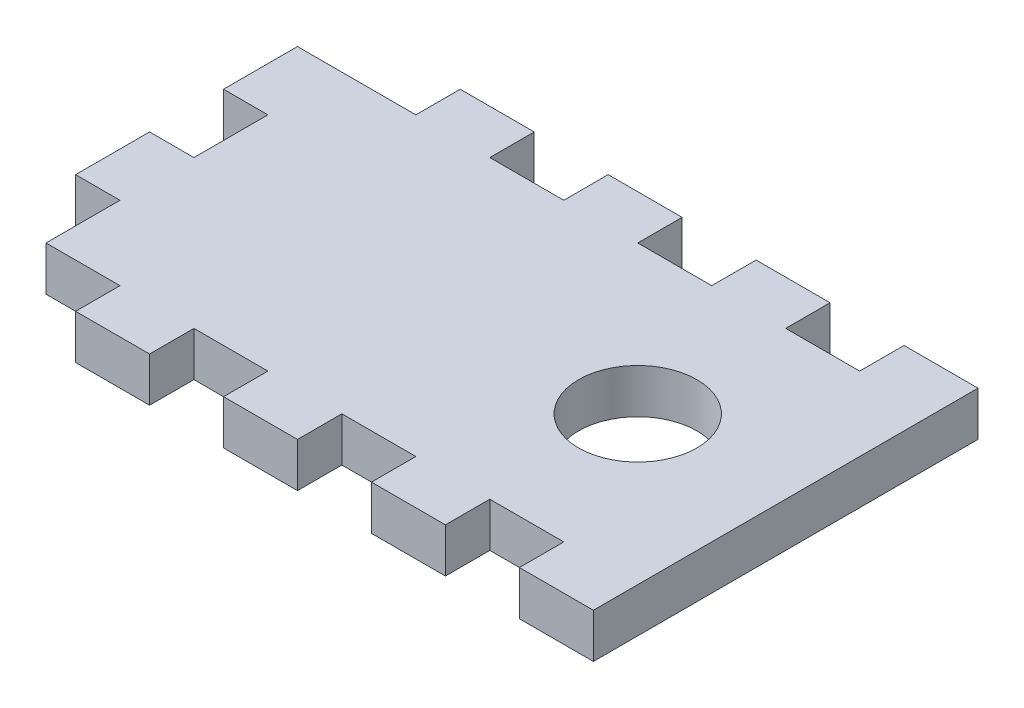
from build123d import *

# Parameters (mm, degrees)
SKETCH1_W           = 40
SKETCH1_H           = 26
BOSS_EXTRUDE1_DEPTH = 1.5
SKETCH2_R           = 4
CUT_EXTRUDE1_DEPTH  = 3
SKETCH8_W           = 5
SKETCH8_H           = 3
BOSS_EXTRUDE7_DEPTH = 3
SKETCH9_W           = 5
SKETCH9_H           = 3
CUT_EXTRUDE2_DEPTH  = 3


with BuildPart() as part:
    # Sketch1 → Boss-Extrude1 (new body, symmetric)
    with BuildSketch(Plane(origin=(0, 0, 0), x_dir=(1, 0, 0), z_dir=(0, 1, 0))):
        Rectangle(SKETCH1_W, SKETCH1_H)
    extrude(amount=BOSS_EXTRUDE1_DEPTH, both=True)

    # Sketch2 → Cut-Extrude1 (cut)
    with BuildSketch(Plane.XZ.offset(1.5)):
        with Locations((10, 0)):
            Circle(SKETCH2_R)
    extrude(amount=-CUT_EXTRUDE1_DEPTH, mode=Mode.SUBTRACT)

    # Sketch8 → Boss-Extrude7 (add)
    with BuildSketch(Plane.ZY.offset(20)):
        with Locations((-7.5, 0)):
            Rectangle(SKETCH8_W, SKETCH8_H)
        with Locations((2.5, 0)):
            Rectangle(SKETCH8_W, SKETCH8_H)
    extrude(amount=BOSS_EXTRUDE7_DEPTH)

    # Sketch9 → Cut-Extrude2 (cut)
    with BuildSketch(Plane.XZ.offset(1.5)):
        with Locations((-17.5, -11.5)):
            Rectangle(SKETCH9_W, SKETCH9_H)
        with Locations((-7.5, -11.5)):
            Rectangle(SKETCH9_W, SKETCH9_H)
        with Locations((-17.5, 11.5)):
            Rectangle(SKETCH9_W, SKETCH9_H)
        with Locations((-7.5, 11.5)):
            Rectangle(SKETCH9_W, SKETCH9_H)
        with Locations((2.5, 11.5)):
            Rectangle(SKETCH9_W, SKETCH9_H)
        with Locations((12.5, 11.5)):
            Rectangle(SKETCH9_W, SKETCH9_H)
        with Locations((2.5, -11.5)):
            Rectangle(SKETCH9_W, SKETCH9_H)
        with Locations((12.5, -11.5)):
            Rectangle(SKETCH9_W, SKETCH9_H)
    extrude(amount=-CUT_EXTRUDE2_DEPTH, mode=Mode.SUBTRACT)


solid = part.part
